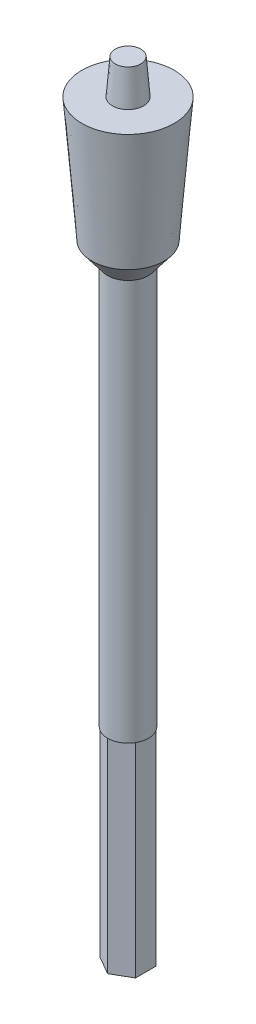
from build123d import *

# Parameters (mm, degrees)
SKETCH2_R          = 4.388085687
CUT_EXTRUDE1_DEPTH = 35
SKETCH4_R          = 12.137505268
CUT_EXTRUDE2_DEPTH = 19.362331983


with BuildPart() as part:
    # Sketch1 → Revolve1 (revolve)
    with BuildSketch(Plane.XY):
        Polygon((0, 0), (0, 153), (0.726418921, 153), (2.686091777, 128.637668017), (7.918657935, 128.637668017), (6.213660545, 107.320079818), (3.5, 103.794837091), (3.5, 55), (3.5, 53), (3.5, 0), align=None)
    revolve(axis=Axis((0, 0, 0), (0, 1, 0)))

    # Sketch2 → Cut-Extrude1 (cut)
    with BuildSketch(Plane.XZ):
        Circle(SKETCH2_R)
        Polygon((0, 3.5), (-3.031088913, 1.75), (-3.031088913, -1.75), (0, -3.5), (3.031088913, -1.75), (3.031088913, 1.75), align=None, mode=Mode.SUBTRACT)
    extrude(amount=-CUT_EXTRUDE1_DEPTH, mode=Mode.SUBTRACT)

    # Sketch4 → Cut-Extrude2 (cut, through all)
    with BuildSketch(Plane(origin=(0, 134.637668017, 0), x_dir=(1, 0, 0), z_dir=(0, 1, 0))):
        Circle(SKETCH4_R)
    extrude(amount=CUT_EXTRUDE2_DEPTH, mode=Mode.SUBTRACT)


solid = part.part
